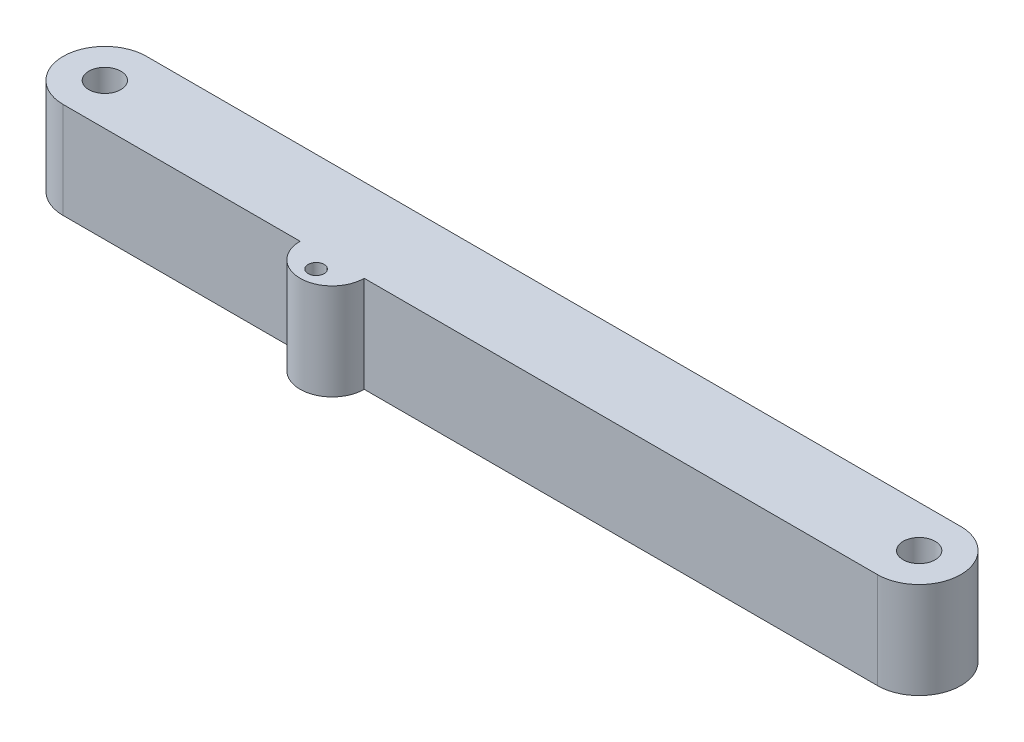
from build123d import *

# Parameters (mm, degrees)
SKETCH1_R           = 3.175
BOSS_EXTRUDE1_DEPTH = 19.05
SKETCH2_R           = 6.35
SKETCH2_R_2         = 1.5875
BOSS_EXTRUDE2_DEPTH = 19.05


with BuildPart() as part:
    # Sketch1 → Boss-Extrude1 (new body)
    with BuildSketch(Plane(origin=(0, 0, 0), x_dir=(1, 0, 0), z_dir=(0, 1, 0))):
        with BuildLine():
            Line((-80.645, -8.255), (80.645, -8.255))
            ThreePointArc((80.645, -8.255), (88.9, 0), (80.645, 8.255))
            Line((80.645, 8.255), (-80.645, 8.255))
            ThreePointArc((-80.645, 8.255), (-88.9, 0), (-80.645, -8.255))
        make_face()
        with Locations((-80.645, 0)):
            Circle(SKETCH1_R, mode=Mode.SUBTRACT)
        with Locations((80.645, 0)):
            Circle(SKETCH1_R, mode=Mode.SUBTRACT)
    extrude(amount=BOSS_EXTRUDE1_DEPTH)

    # Sketch2 → Boss-Extrude2 (add)
    with BuildSketch(Plane(origin=(0, 19.05, 0), x_dir=(1, 0, 0), z_dir=(0, 1, 0))):
        with Locations((-27.363899298, -8.255)):
            Circle(SKETCH2_R)
        with Locations((-27.363899298, -11.43)):
            Circle(SKETCH2_R_2, mode=Mode.SUBTRACT)
    extrude(amount=-BOSS_EXTRUDE2_DEPTH)


solid = part.part
